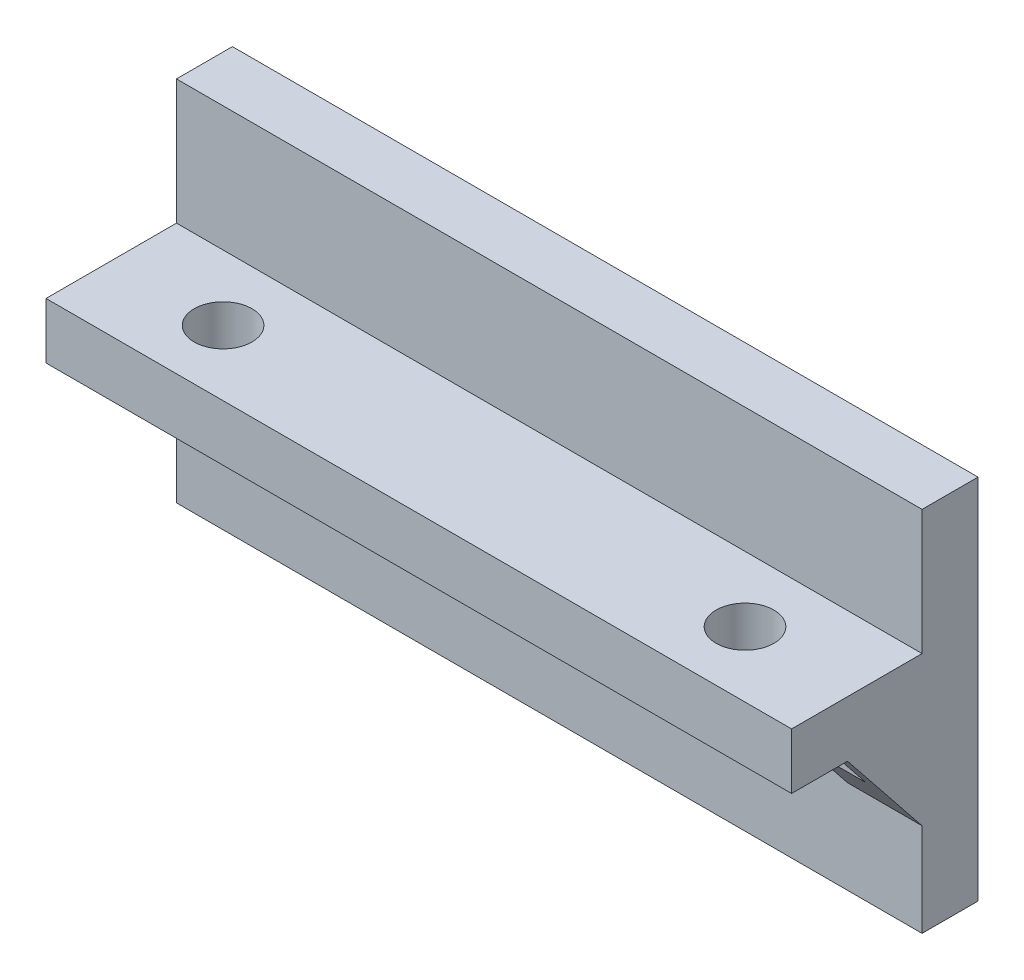
from build123d import *

# Parameters (mm, degrees)
SKETCH_1_W          = 40
SKETCH_1_H          = 6.7
EXTRUDE_1_DEPTH     = 3
SKETCH_1_3_W        = 40
SKETCH_1_3_H        = 10
SKETCH_1_3_R        = 1.55
EXTRUDE_2_DEPTH     = 3
SKETCH_1_5_W        = 40
SKETCH_1_5_H        = 3
EXTRUDE_3_DEPTH     = 10
SKETCH_2_R          = 1.55
CUT_EXTRUDE_1_DEPTH = 3
SKETCH_3_W          = 6
SKETCH_3_H          = 2
EXTRUDE_4_DEPTH     = 5
CUT_EXTRUDE_2_DEPTH = 44


with BuildPart() as part:
    # 草图1 → 凸台-拉伸1 (new body)
    with BuildSketch(Plane.XY):
        with Locations((20, 16.35)):
            Rectangle(SKETCH_1_W, SKETCH_1_H)
    extrude(amount=EXTRUDE_1_DEPTH)



with BuildPart() as body_2:
    # 草图1<3> → 凸台-拉伸2 (new body)
    with BuildSketch(Plane.XY):
        with Locations((20, 5)):
            Rectangle(SKETCH_1_3_W, SKETCH_1_3_H)
        with Locations((10, 5)):
            Circle(SKETCH_1_3_R, mode=Mode.SUBTRACT)
        with Locations((30, 5)):
            Circle(SKETCH_1_3_R, mode=Mode.SUBTRACT)
    extrude(amount=EXTRUDE_2_DEPTH)


with BuildPart() as part_1:
    add(part.part)

    add(body_2.part)  # 凸台-拉伸3 merges body 2
    # 草图1<5> → 凸台-拉伸3 (add)
    with BuildSketch(Plane.XY):
        with Locations((20, 11.5)):
            Rectangle(SKETCH_1_5_W, SKETCH_1_5_H)
    extrude(amount=EXTRUDE_3_DEPTH)

    # 草图2 → 切除-拉伸1 (cut)
    with BuildSketch(Plane(origin=(0, 13, 0), x_dir=(1, 0, 0), z_dir=(0, 1, 0))):
        with Locations((6, -6.5)):
            Circle(SKETCH_2_R)
        with Locations((34, -6.5)):
            Circle(SKETCH_2_R)
    extrude(amount=-CUT_EXTRUDE_1_DEPTH, mode=Mode.SUBTRACT)

    # 草图3 → 凸台-拉伸4 (add)
    with BuildSketch(Plane.XZ.offset(-10)):
        Polygon((0, 7), (0, 3), (4, 3), (4, 5), (1, 5), (1, 7), align=None)
        with Locations((20.5, 4)):
            Rectangle(SKETCH_3_W, SKETCH_3_H)
        Polygon((36, 5), (36, 3), (40, 3), (40, 7), (39, 7), (39, 5), align=None)
    extrude(amount=EXTRUDE_4_DEPTH)

    # 草图4 → 切除-拉伸2 (cut)
    with BuildSketch(Plane.ZY):
        Polygon((7, 10), (3, 5), (7, 5), align=None)
    extrude(amount=-CUT_EXTRUDE_2_DEPTH, mode=Mode.SUBTRACT)


solid = part_1.part
